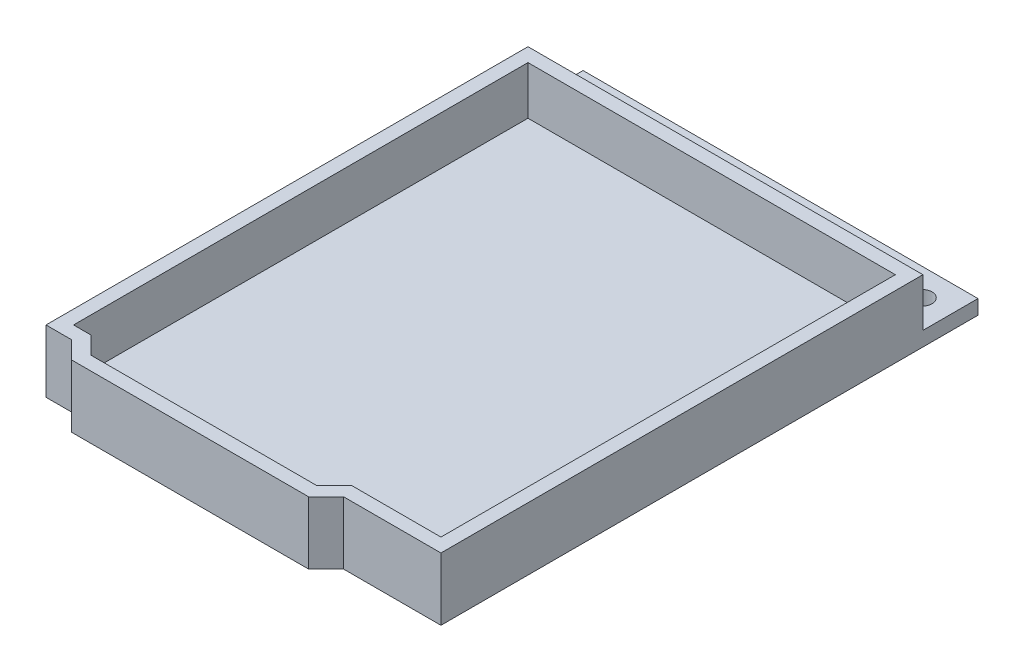
from build123d import *

# Parameters (mm, degrees)
BOSS_EXTRUDE1_DEPTH = 2.1
SKETCH2_W           = 57.36
SKETCH2_H           = 70
BOSS_EXTRUDE2_DEPTH = 7
SKETCH3_W           = 53.36
SKETCH3_H           = 66
CUT_EXTRUDE1_DEPTH  = 7
SKETCH4_R           = 1.5
CUT_EXTRUDE2_DEPTH  = 2.1
SKETCH6_W           = 40.39
SKETCH6_H           = 2
CUT_EXTRUDE3_DEPTH  = 9.1
BOSS_EXTRUDE3_DEPTH = 9.1
BOSS_EXTRUDE4_DEPTH = 2.1


with BuildPart() as part:
    # Sketch1 → Boss-Extrude1 (new body)
    with BuildSketch(Plane(origin=(0, 0, 0), x_dir=(1, 0, 0), z_dir=(0, 1, 0))):
        Polygon((28.68, 0), (28.68, -8), (28.68, -78), (-28.68, -78), (-28.68, 0), align=None)
    extrude(amount=BOSS_EXTRUDE1_DEPTH)

    # Sketch2 → Boss-Extrude2 (add)
    with BuildSketch(Plane(origin=(0, 2.1, 0), x_dir=(1, 0, 0), z_dir=(0, 1, 0))):
        with Locations((0, -43)):
            Rectangle(SKETCH2_W, SKETCH2_H)
    extrude(amount=BOSS_EXTRUDE2_DEPTH)

    # Sketch3 → Cut-Extrude1 (cut)
    with BuildSketch(Plane(origin=(0, 9.1, 0), x_dir=(1, 0, 0), z_dir=(0, 1, 0))):
        with Locations((0, -43)):
            Rectangle(SKETCH3_W, SKETCH3_H)
    extrude(amount=-CUT_EXTRUDE1_DEPTH, mode=Mode.SUBTRACT)

    # Sketch4 → Cut-Extrude2 (cut)
    with BuildSketch(Plane(origin=(0, 2.1, 0), x_dir=(1, 0, 0), z_dir=(0, 1, 0))):
        with Locations((24.5, -4)):
            Circle(SKETCH4_R)
        with Locations((-24.5, -4)):
            Circle(SKETCH4_R)
    extrude(amount=-CUT_EXTRUDE2_DEPTH, mode=Mode.SUBTRACT)

    # Sketch6 → Cut-Extrude3 (cut)
    with BuildSketch(Plane(origin=(0, 9.1, 0), x_dir=(1, 0, 0), z_dir=(0, 1, 0))):
        with Locations((-6.485, -77)):
            Rectangle(SKETCH6_W, SKETCH6_H)
    extrude(amount=-CUT_EXTRUDE3_DEPTH, mode=Mode.SUBTRACT)

    # Sketch5 → Boss-Extrude3 (add)
    with BuildSketch(Plane(origin=(0, 9.1, 0), x_dir=(1, 0, 0), z_dir=(0, 1, 0))):
        Polygon((-26.68, -76), (-24.14, -76), (-21.6, -78.54), (11.17, -78.54), (13.71, -76), (14.538427125, -76), (14.538427125, -78), (11.998427125, -80.54), (-22.428427125, -80.54), (-24.968427125, -78), (-26.68, -78), align=None)
    extrude(amount=-BOSS_EXTRUDE3_DEPTH)

    # Sketch7 → Boss-Extrude4 (add)
    with BuildSketch(Plane.XZ):
        Polygon((13.71, 76), (-24.14, 76), (-21.6, 78.54), (11.17, 78.54), align=None)
    extrude(amount=-BOSS_EXTRUDE4_DEPTH)


solid = part.part
